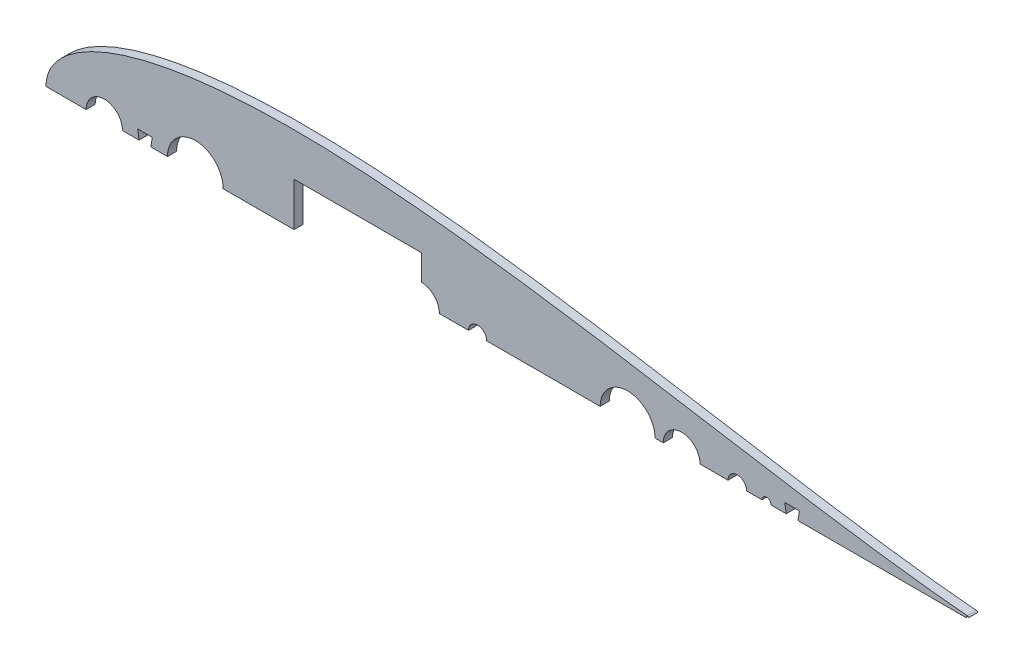
from build123d import *

# Parameters (mm, degrees)
BOSS_EXTRUDE1_DEPTH     = 6.35
CUT_EXTRUDE1_DEPTH      = 1.0000001
CUT_EXTRUDE1_DEPTH_BACK = 7.3500001
SKETCH4_W               = 6.35
SKETCH4_H               = 6.35
SKETCH4_H_2             = 12.7
CUT_EXTRUDE2_DEPTH      = 6.35
SKETCH7_W               = 88.9
SKETCH7_H               = 60.96
CUT_EXTRUDE4_DEPTH      = 7.3500001
SKETCH8_R               = 1.2446
CUT_EXTRUDE5_DEPTH      = 7.3500001


with BuildPart() as part:
    # Sketch2 → Boss-Extrude1 (new body)
    with BuildSketch(Plane.XY):
        with BuildLine():
            ThreePointArc((84.709, 0), (104.14, 19.431), (123.571, 0))
            Line((123.571, 0), (460.660965279, 0))
            Line((460.660965279, 0), (473.360965279, 0))
            Line((473.360965279, 0), (643.966787522, 0))
            ThreePointArc((643.966787522, 0), (643.547407924, 1.075012082), (642.510849283, 1.582039112))
            add(Edge.make_bspline(
                [(642.510849283, 1.582039112), (641.993392355, 1.625070631), (638.093728429, 1.953546407), (630.413817462, 2.663385493), (619.014124193, 3.849253664), (606.374988512, 5.304428983), (592.543922516, 7.037634907), (577.585454095, 9.050636147), (561.564270734, 11.338919625), (544.549749946, 13.890665375), (526.614143658, 16.687720753), (507.832591566, 19.705111663), (488.282710288, 22.911672601), (468.044367735, 26.27043606), (447.199424328, 29.739007432), (425.831595832, 33.270324121), (404.02631566, 36.813220545), (381.870662856, 40.313266856), (359.453314895, 43.713502532), (336.86454415, 46.955447457), (314.196207315, 49.979843895), (291.541767704, 52.727712704), (268.996310773, 55.141201012), (246.65655865, 57.164603829), (224.620860897, 58.745176641), (202.989192599, 59.8341217), (181.863132616, 60.387506142), (161.345829027, 60.366961324), (141.542033828, 59.739895824), (122.558104573, 58.481758104), (104.502313427, 56.574303932), (87.485018636, 54.008935199), (71.619696083, 50.784752003), (57.023709725, 46.912543066), (43.82045433, 42.41500246), (32.141645239, 37.332204029), (22.129107375, 31.731455339), (13.932423524, 25.726412106), (7.689616489, 19.513207632), (3.463136343, 13.420354421), (1.106333228, 7.923389435), (0.154611582, 3.513796615), (0, 1.007496172), (0, 0)],
                knots=[0.020157042, 0.020157042, 0.020157042, 0.020157042, 0.021270888, 0.028552555, 0.036780684, 0.045920102, 0.055931764, 0.066772884, 0.07839713, 0.090754827, 0.103793165, 0.117456432, 0.131686226, 0.146421738, 0.161599998, 0.177156133, 0.193023668, 0.209134786, 0.225420633, 0.241811602, 0.258237647, 0.274628557, 0.290914287, 0.307025229, 0.322892517, 0.338448342, 0.353626207, 0.368361232, 0.382590428, 0.396252961, 0.409290412, 0.42164701, 0.433269881, 0.444109249, 0.45411864, 0.463255055, 0.471479114, 0.478755289, 0.485052318, 0.490344026, 0.494609833, 0.497833231, 0.5, 0.5, 0.5, 0.5], degree=3))
            Line((0, 0), (27.94, 0))
            ThreePointArc((27.94, 0), (40.64, 12.7), (53.34, 0))
            Line((53.34, 0), (84.709, 0))
        make_face()
    extrude(amount=BOSS_EXTRUDE1_DEPTH)

    # Sketch3 → Cut-Extrude1 (cut, two sides)
    with BuildSketch(Plane.XY.offset(6.35)) as cut_extrude1_sk:
        with BuildLine():
            ThreePointArc((424.777212339, 0), (405.60179385, 18.930718125), (386.426375361, 0))
            Line((386.426375361, 0), (424.777212339, 0))
        make_face()
        with BuildLine():
            Line((424.777212339, 0), (386.426375361, 0))
            ThreePointArc((386.426375361, 0), (405.478650373, -19.422886493), (424.77879385, -0.246281875))
            ThreePointArc((424.77879385, -0.246281875), (424.778398468, -0.123138399), (424.777212339, 0))
        make_face()
        with BuildLine():
            ThreePointArc((456.128866123, 0), (443.301866123, 12.827), (430.474866123, 0))
            Line((430.474866123, 0), (456.128866123, 0))
        make_face()
        with BuildLine():
            Line((456.128866123, 0), (430.474866123, 0))
            ThreePointArc((430.474866123, 0), (443.301866123, -12.827), (456.128866123, 0))
        make_face()
        with BuildLine():
            ThreePointArc((488.559534569, 0), (482.082534569, 6.477), (475.605534569, 0))
            Line((475.605534569, 0), (488.559534569, 0))
        make_face()
        with BuildLine():
            Line((488.559534569, 0), (475.605534569, 0))
            ThreePointArc((475.605534569, 0), (482.082534569, -6.477), (488.559534569, 0))
        make_face()
        with BuildLine():
            ThreePointArc((505.649992416, 0), (502.474992416, 3.175), (499.299992416, 0))
            Line((499.299992416, 0), (505.649992416, 0))
        make_face()
        with BuildLine():
            Line((505.649992416, 0), (499.299992416, 0))
            ThreePointArc((499.299992416, 0), (502.474992417, -3.175), (505.649992416, 0))
        make_face()
        with BuildLine():
            Line((274.32, 0), (248.92, 0))
            ThreePointArc((248.92, 0), (261.62, -12.7), (274.32, 0))
        make_face()
        with BuildLine():
            ThreePointArc((274.32, 0), (261.62, 12.7), (248.92, 0))
            Line((248.92, 0), (274.32, 0))
        make_face()
        with BuildLine():
            Line((294.64, 0), (307.34, 0))
            ThreePointArc((307.34, 0), (300.99, 6.35), (294.64, 0))
        make_face()
        with BuildLine():
            ThreePointArc((294.64, 0), (300.99, -6.35), (307.34, 0))
            Line((307.34, 0), (294.64, 0))
        make_face()
    extrude(amount=CUT_EXTRUDE1_DEPTH, mode=Mode.SUBTRACT)
    extrude(cut_extrude1_sk.sketch, amount=-CUT_EXTRUDE1_DEPTH_BACK, mode=Mode.SUBTRACT)

    # Sketch4 → Cut-Extrude2 (cut)
    with BuildSketch(Plane.XY.offset(6.35)):
        Polygon((63.9445, 6.35), (64.897, 0), (65.8495, 0), (65.8495, 6.35), align=None)
        Polygon((65.8495, 0), (64.897, 0), (65.8495, -6.35), align=None)
        with Locations((69.0245, 3.175)):
            Rectangle(SKETCH4_W, SKETCH4_H)
        with Locations((69.0245, -3.175)):
            Rectangle(SKETCH4_W, SKETCH4_H)
        Polygon((72.1995, 6.35), (72.1995, 0), (73.152, 0), (74.1045, 6.35), align=None)
        Polygon((73.152, 0), (72.1995, 0), (72.1995, -6.35), align=None)
        with Locations((520.309534569, 0)):
            Rectangle(SKETCH4_W, SKETCH4_H_2)
        Polygon((517.134534569, -6.35), (517.134534569, 6.35), (515.229534569, 6.35), align=None)
        Polygon((525.389534569, 6.35), (523.484534569, 6.35), (523.484534569, -6.35), align=None)
    extrude(amount=-CUT_EXTRUDE2_DEPTH, mode=Mode.SUBTRACT)

    # Sketch7 → Cut-Extrude4 (cut, through all)
    with BuildSketch(Plane(origin=(327.95923074, -13.751410445, 6.35), x_dir=(1, 0, 0), z_dir=(0, 0, 1))):
        with Locations((-110.53523074, 13.751410445)):
            Rectangle(SKETCH7_W, SKETCH7_H)
    extrude(amount=-CUT_EXTRUDE4_DEPTH, mode=Mode.SUBTRACT)

    # Sketch8 → Cut-Extrude5 (cut, through all)
    with BuildSketch(Plane(origin=(327.95923074, -13.751410445, 6.35), x_dir=(1, 0, 0), z_dir=(0, 0, 1))):
        with Locations((314.928477568, 13.751410445)):
            Circle(SKETCH8_R)
    extrude(amount=-CUT_EXTRUDE5_DEPTH, mode=Mode.SUBTRACT)


solid = part.part
